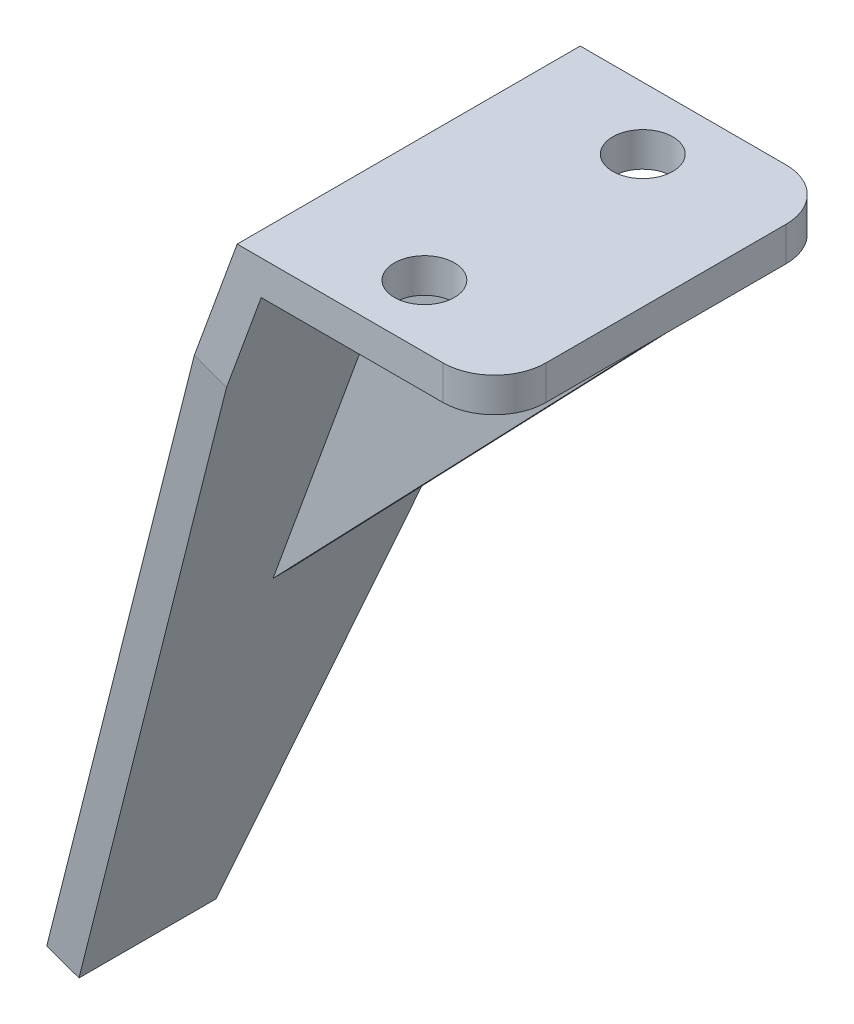
from build123d import *

# Parameters (mm, degrees)
BOSS_EXTRUDE1_DEPTH = 10
BOSS_EXTRUDE2_DEPTH = 1
CHAMFER1_SIZE       = 6
CHAMFER1_SIZE2      = 42.692218334
SKETCH3_R           = 1.75
CUT_EXTRUDE1_DEPTH  = 48.668671326
FILLET1_R           = 3


with BuildPart() as part:
    # Sketch1 → Boss-Extrude1 (new body, symmetric)
    with BuildSketch(Plane.XY):
        Polygon((-7.502714215, -23.495815343), (-9.382099457, -22.811775057), (7.71890771, 24.172855983), (22.71890771, 24.172855983), (22.71890771, 22.172855983), (9.119322786, 22.172855983), align=None)
    extrude(amount=BOSS_EXTRUDE1_DEPTH, both=True)

    # Sketch2 → Boss-Extrude2 (add)
    with BuildSketch(Plane.XY):
        Polygon((22.71890771, 22.172855983), (0.808304286, -0.66147968), (9.119322786, 22.172855983), align=None)
    extrude(amount=BOSS_EXTRUDE2_DEPTH)

    # Chamfer1
    chamfer1_edges = [part.edges().sort_by_distance(p)[0] for p in [
        (-8.442406836, -23.1537952, 10),
        (-8.442406836, -23.1537952, -10),
    ]]
    chamfer1_side = [part.faces().sort_by_distance(p)[0] for p in [
        (-8.442406836, -23.1537952, 0),
    ]]
    chamfer(chamfer1_edges, length=CHAMFER1_SIZE, length2=CHAMFER1_SIZE2, reference=chamfer1_side[0])

    # Sketch3 → Cut-Extrude1 (cut, through all)
    with BuildSketch(Plane(origin=(0, 24.172855983, 0), x_dir=(1, 0, 0), z_dir=(0, 1, 0))):
        with Locations((15, 6.365)):
            Circle(SKETCH3_R)
        with Locations((15, -6.365)):
            Circle(SKETCH3_R)
    extrude(amount=-CUT_EXTRUDE1_DEPTH, mode=Mode.SUBTRACT)

    # Fillet1
    fillet1_edges = [part.edges().sort_by_distance(p)[0] for p in [
        (22.71890771, 23.172855983, 10),
        (22.71890771, 23.172855983, -10),
    ]]
    fillet(fillet1_edges, radius=FILLET1_R)


solid = part.part
